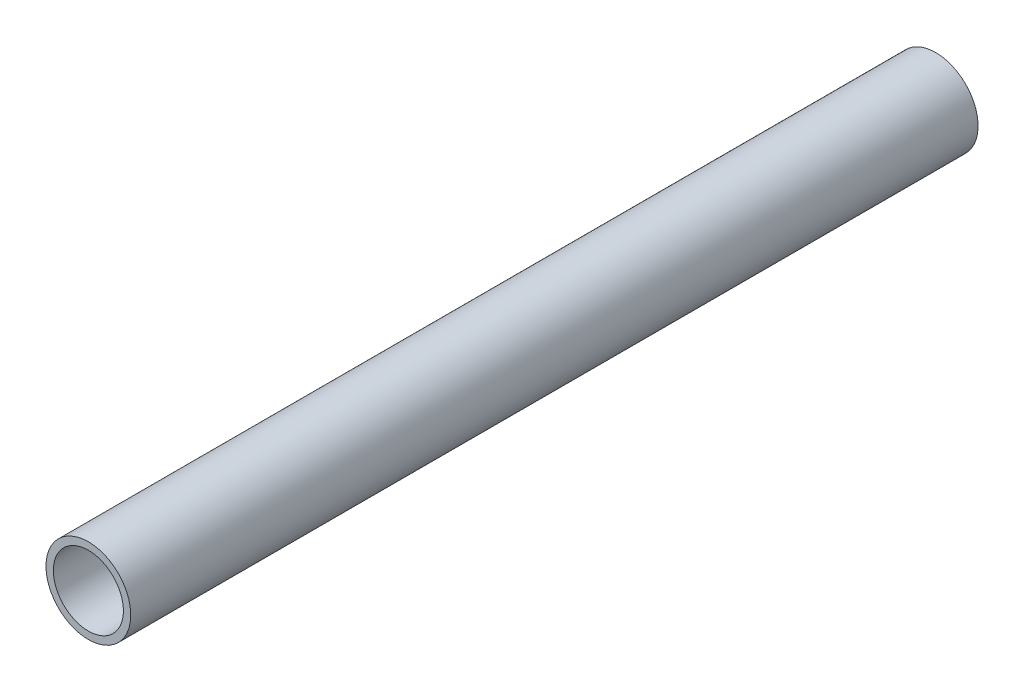
from build123d import *

# Parameters (mm, degrees)
SKETCH1_W = 190.5
SKETCH1_H = 1.651


with BuildPart() as part:
    # Sketch1 → Revolve1 (revolve)
    with BuildSketch(Plane(origin=(0, 0, 0), x_dir=(0, 0, -1), z_dir=(1, 0, 0))):
        with Locations((0, 8.6995)):
            Rectangle(SKETCH1_W, SKETCH1_H)
    revolve(axis=Axis((0, 0, 0), (0, 0, 1)))


solid = part.part
